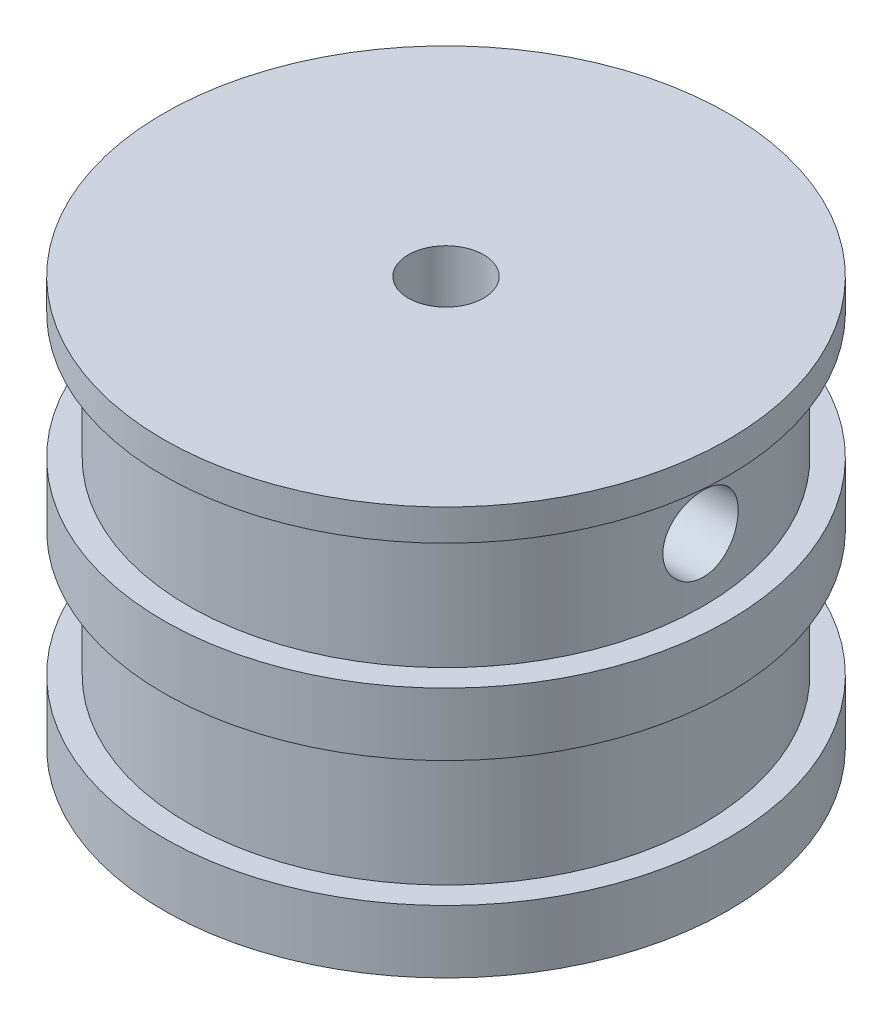
from build123d import *

# Parameters (mm, degrees)
SKETCH1_R               = 22.5
BOSS_EXTRUDE1_DEPTH     = 60
SKETCH2_R               = 15
CUT_EXTRUDE1_DEPTH      = 12
SKETCH6_W               = 2
SKETCH6_H               = 10
SKETCH7_R               = 22.5
CUT_EXTRUDE2_DEPTH      = 27.5
SKETCH8_R               = 15
CUT_EXTRUDE3_DEPTH      = 27.5
SKETCH9_R               = 2
CUT_EXTRUDE5_DEPTH      = 23.5
CUT_EXTRUDE5_DEPTH_BACK = 23.5
SKETCH10_R              = 15
BOSS_EXTRUDE2_DEPTH     = 32.5
SKETCH11_R              = 3
CUT_EXTRUDE8_DEPTH      = 23.5
CUT_EXTRUDE8_DEPTH_BACK = 23.5
SKETCH12_R              = 3
CUT_EXTRUDE9_DEPTH      = 32.5


with BuildPart() as part:
    # Sketch1 → Boss-Extrude1 (new body)
    with BuildSketch(Plane(origin=(0, 0, 0), x_dir=(1, 0, 0), z_dir=(0, 1, 0))):
        Circle(SKETCH1_R)
    extrude(amount=BOSS_EXTRUDE1_DEPTH)

    # Sketch2 → Cut-Extrude1 (cut)
    with BuildSketch(Plane(origin=(0, 60, 0), x_dir=(1, 0, 0), z_dir=(0, 1, 0))):
        Circle(SKETCH2_R)
    extrude(amount=-CUT_EXTRUDE1_DEPTH, mode=Mode.SUBTRACT)

    # Sketch6 → Cut-Revolve1 (revolve, cut)
    with BuildSketch(Plane.XY):
        with Locations((-21.5, 52.5)):
            Rectangle(SKETCH6_W, SKETCH6_H)
        with Locations((-21.5, 37.5)):
            Rectangle(SKETCH6_W, SKETCH6_H)
        with Locations((-21.5, 22.5)):
            Rectangle(SKETCH6_W, SKETCH6_H)
        with Locations((-21.5, 7.5)):
            Rectangle(SKETCH6_W, SKETCH6_H)
    revolve(axis=Axis((0, 0, 0), (0, 1, 0)), mode=Mode.SUBTRACT)

    # Sketch7 → Cut-Extrude2 (cut)
    with BuildSketch(Plane.XZ):
        Circle(SKETCH7_R)
    extrude(amount=-CUT_EXTRUDE2_DEPTH, mode=Mode.SUBTRACT)

    # Sketch8 → Cut-Extrude3 (cut)
    with BuildSketch(Plane(origin=(0, 48, 0), x_dir=(1, 0, 0), z_dir=(0, 1, 0))):
        Circle(SKETCH8_R)
    extrude(amount=-CUT_EXTRUDE3_DEPTH, mode=Mode.SUBTRACT)

    # Sketch9 → Cut-Extrude5 (cut, two sides)
    with BuildSketch(Plane(origin=(0, 0, 0), x_dir=(0, 0, -1), z_dir=(1, 0, 0))) as cut_extrude5_sk:
        with Locations((0, 52.5)):
            Circle(SKETCH9_R)
    extrude(amount=CUT_EXTRUDE5_DEPTH, mode=Mode.SUBTRACT)
    extrude(cut_extrude5_sk.sketch, amount=-CUT_EXTRUDE5_DEPTH_BACK, mode=Mode.SUBTRACT)

    # Sketch10 → Boss-Extrude2 (add)
    with BuildSketch(Plane(origin=(0, 60, 0), x_dir=(1, 0, 0), z_dir=(0, 1, 0))):
        Circle(SKETCH10_R)
    extrude(amount=-BOSS_EXTRUDE2_DEPTH)

    # Sketch11 → Cut-Extrude8 (cut, two sides)
    with BuildSketch(Plane(origin=(0, 0, 0), x_dir=(0, 0, -1), z_dir=(1, 0, 0))) as cut_extrude8_sk:
        with Locations((0, 52.5)):
            Circle(SKETCH11_R)
    extrude(amount=CUT_EXTRUDE8_DEPTH, mode=Mode.SUBTRACT)
    extrude(cut_extrude8_sk.sketch, amount=-CUT_EXTRUDE8_DEPTH_BACK, mode=Mode.SUBTRACT)

    # Sketch12 → Cut-Extrude9 (cut)
    with BuildSketch(Plane(origin=(0, 60, 0), x_dir=(1, 0, 0), z_dir=(0, 1, 0))):
        Circle(SKETCH12_R)
    extrude(amount=-CUT_EXTRUDE9_DEPTH, mode=Mode.SUBTRACT)


solid = part.part
